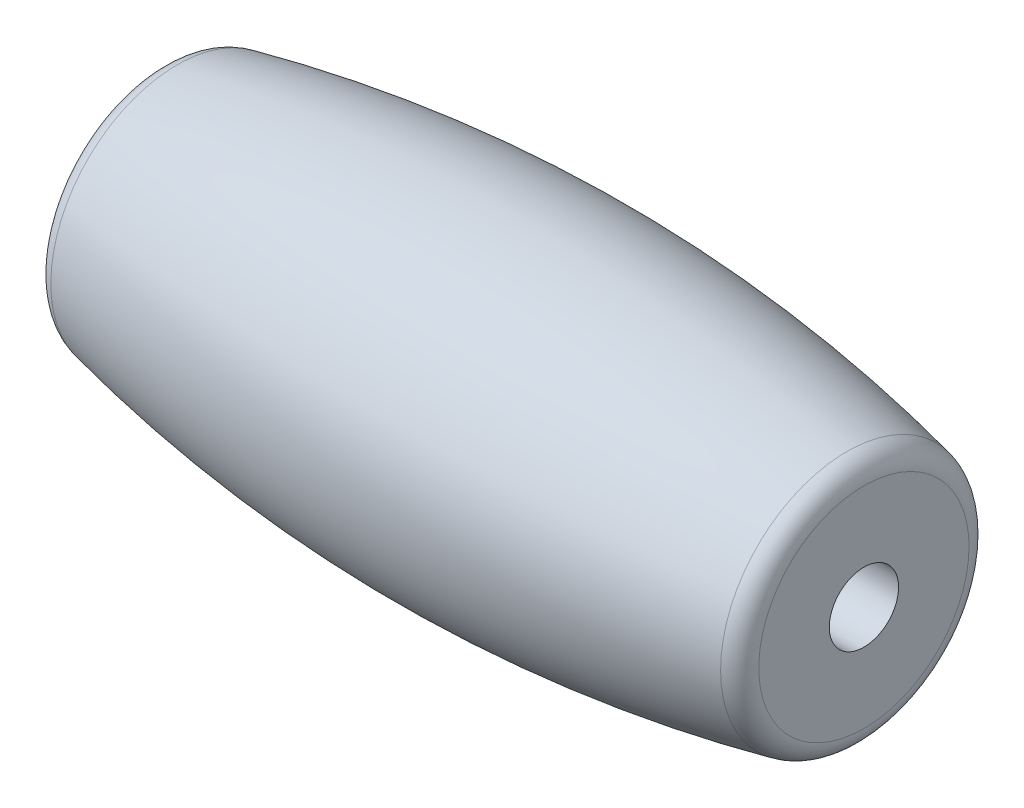
from build123d import *

# Parameters (mm, degrees)
SKETCH2_R                = 5.655413805
SKETCH2_R_2              = 1.6
BOSS_EXTRUDE1_DEPTH      = 16.25
BOSS_EXTRUDE1_DEPTH_BACK = 16.25
FILLET1_R                = 1


with BuildPart() as part:
    # Sketch1 → Revolve1 (revolve)
    with BuildSketch(Plane.XY):
        with BuildLine():
            ThreePointArc((16.25, 5.655413805), (0, 7.5), (-16.25, 5.655413805))
            Line((-16.25, 5.655413805), (16.25, 5.655413805))
        make_face()
    revolve(axis=Axis((-32.113081447, 0, 0), (1, 0, 0)))

    # Sketch2 → Boss-Extrude1 (add, two sides)
    with BuildSketch(Plane(origin=(0, 0, 0), x_dir=(0, 0, -1), z_dir=(1, 0, 0))) as boss_extrude1_sk:
        Circle(SKETCH2_R)
        Circle(SKETCH2_R_2, mode=Mode.SUBTRACT)
    extrude(amount=BOSS_EXTRUDE1_DEPTH)
    extrude(boss_extrude1_sk.sketch, amount=-BOSS_EXTRUDE1_DEPTH_BACK)

    # Fillet1
    fillet1_edges = [part.edges().sort_by_distance(p)[0] for p in [
        (-16.25, -5.655413805, 0),
        (16.25, -5.655413805, 0),
    ]]
    fillet(fillet1_edges, radius=FILLET1_R)


solid = part.part
